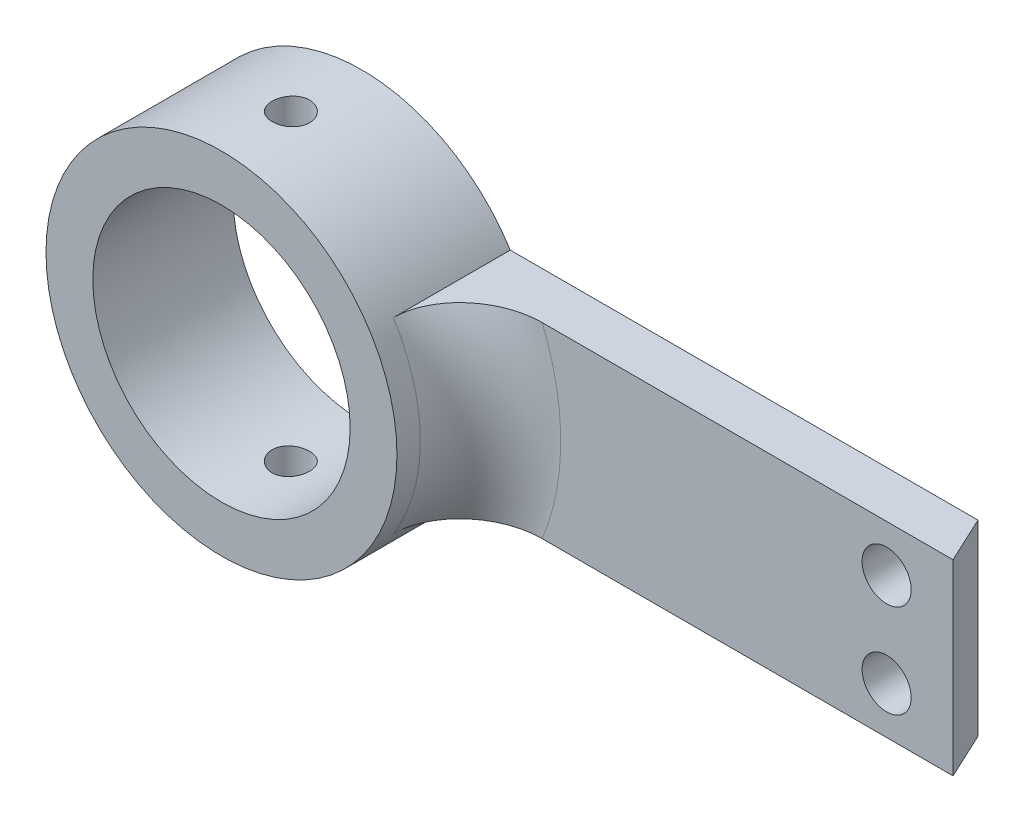
from build123d import *

# Parameters (mm, degrees)
BOSS_EXTRUDE1_DEPTH     = 8
SKETCH6_R               = 7.5
BOSS_EXTRUDE3_DEPTH     = 6
SKETCH2_R               = 5.5
CUT_EXTRUDE4_DEPTH      = 5
CUT_EXTRUDE4_DEPTH_BACK = 3
SKETCH8_R               = 0.8
CUT_EXTRUDE5_DEPTH      = 16
FILLET3_R               = 3
SKETCH9_R               = 1.05
CUT_EXTRUDE6_DEPTH      = 3.0000001


with BuildPart() as part:
    # Sketch1 → Boss-Extrude1 (new body)
    with BuildSketch(Plane(origin=(0, 0, 0), x_dir=(1, 0, 0), z_dir=(0, 1, 0))):
        Polygon((0, 0), (0, 2), (26.334414729, 2), (27.267030045, 0), (21.996962058, 0), align=None)
    extrude(amount=BOSS_EXTRUDE1_DEPTH)

    # Sketch6 → Boss-Extrude3 (add)
    with BuildSketch(Plane(origin=(0, 0, -2), x_dir=(-1, 0, 0), z_dir=(0, 0, -1))):
        with Locations((0, 4)):
            Circle(SKETCH6_R)
    extrude(amount=-BOSS_EXTRUDE3_DEPTH)

    # Sketch2 → Cut-Extrude4 (cut, two sides)
    with BuildSketch(Plane.XY) as cut_extrude4_sk:
        with Locations((0, 4)):
            Circle(SKETCH2_R)
    extrude(amount=CUT_EXTRUDE4_DEPTH, mode=Mode.SUBTRACT)
    extrude(cut_extrude4_sk.sketch, amount=-CUT_EXTRUDE4_DEPTH_BACK, mode=Mode.SUBTRACT)

    # Sketch8 → Cut-Extrude5 (cut, through all)
    with BuildSketch(Plane(origin=(0, -3.5, 0), x_dir=(-1, 0, 0), z_dir=(0, -1, 0))):
        with Locations((0, -1.034043254)):
            Circle(SKETCH8_R)
    extrude(amount=-CUT_EXTRUDE5_DEPTH, mode=Mode.SUBTRACT)

    # Fillet3
    fillet3_edges = [part.edges().sort_by_distance(p)[0] for p in [
        (7.5, 4, 0),
    ]]
    fillet(fillet3_edges, radius=FILLET3_R)

    # Sketch9 → Cut-Extrude6 (cut, through all)
    with BuildSketch(Plane.XY):
        with Locations((24.429577374, 2)):
            Circle(SKETCH9_R)
        with Locations((24.429577374, 6)):
            Circle(SKETCH9_R)
    extrude(amount=-CUT_EXTRUDE6_DEPTH, mode=Mode.SUBTRACT)


solid = part.part
